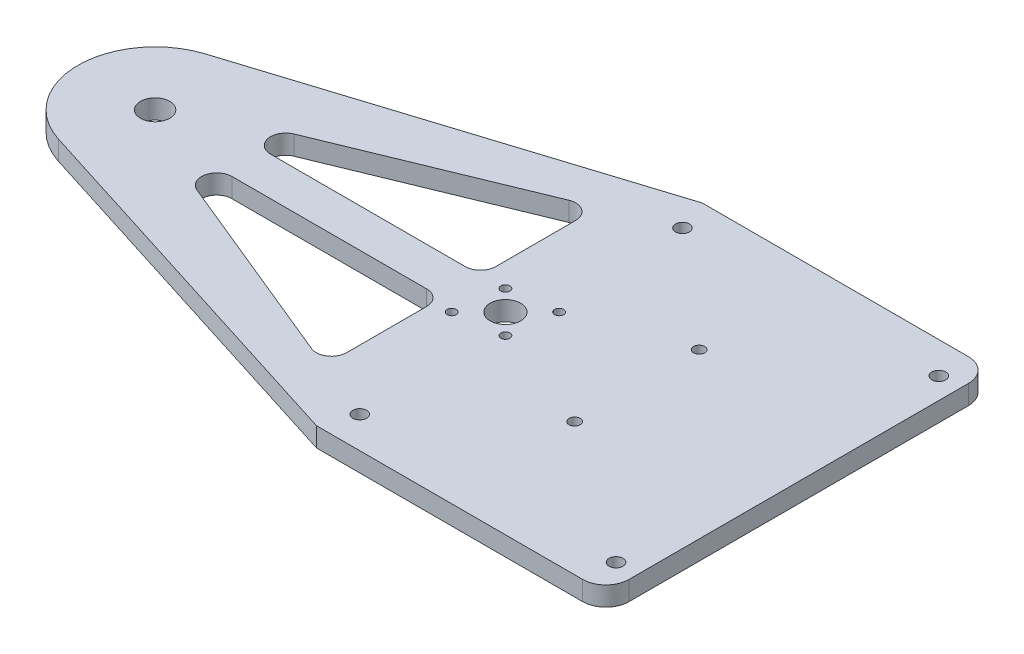
from build123d import *

# Parameters (mm, degrees)
SKETCH1_W           = 95.25
SKETCH1_H           = 127
BOSS_EXTRUDE1_DEPTH = 6.35
BOSS_EXTRUDE3_DEPTH = 6.35
SKETCH5_R           = 4.826
SKETCH5_R_2         = 5.039999953
SKETCH5_R_3         = 1.5
CUT_EXTRUDE1_DEPTH  = 7.35
CUT_EXTRUDE2_DEPTH  = 7.35
FILLET9_R           = 5
FILLET10_R          = 7.62
SKETCH7_R           = 2.2812375
CUT_EXTRUDE3_DEPTH  = 7.35
SKETCH8_R           = 1.830008083
CUT_EXTRUDE4_DEPTH  = 7.35


with BuildPart() as part:
    # Sketch1 → Boss-Extrude1 (new body)
    with BuildSketch(Plane(origin=(0, 0, 0), x_dir=(1, 0, 0), z_dir=(0, 1, 0))):
        Rectangle(SKETCH1_W, SKETCH1_H)
    extrude(amount=BOSS_EXTRUDE1_DEPTH)

    # Sketch4 → Boss-Extrude3 (add)
    with BuildSketch(Plane(origin=(0, 6.35, 0), x_dir=(1, 0, 0), z_dir=(0, 1, 0))):
        with BuildLine():
            Line((-47.625, 63.5), (-171.916018217, 24.219268021))
            ThreePointArc((-171.916018217, 24.219268021), (-189.6618, 0), (-171.916018217, -24.219268021))
            Line((-171.916018217, -24.219268021), (-47.625, -63.5))
            Line((-47.625, -63.5), (-47.625, 63.5))
        make_face()
    extrude(amount=-BOSS_EXTRUDE3_DEPTH)

    # Sketch5 → Cut-Extrude1 (cut, through all)
    with BuildSketch(Plane(origin=(0, 6.35, 0), x_dir=(1, 0, 0), z_dir=(0, 1, 0))):
        with Locations((-164.2618, 0)):
            Circle(SKETCH5_R)
        with Locations((-48.9458, 0)):
            Circle(SKETCH5_R_2)
        with Locations((-40.106965235, 8.838834765)):
            Circle(SKETCH5_R_3)
        with Locations((-57.784634765, -8.838834765)):
            Circle(SKETCH5_R_3)
        with Locations((-55.663314421, 6.717514421)):
            Circle(SKETCH5_R_3)
        with Locations((-42.228285579, -6.717514421)):
            Circle(SKETCH5_R_3)
    extrude(amount=-CUT_EXTRUDE1_DEPTH, mode=Mode.SUBTRACT)

    # Sketch6 → Cut-Extrude2 (cut, through all)
    with BuildSketch(Plane(origin=(0, 6.35, 0), x_dir=(1, 0, 0), z_dir=(0, 1, 0))):
        Polygon((-63.5, 45.163743355), (-157.9118, 6.35), (-63.5, 6.35), align=None)
        Polygon((-63.5, -6.35), (-63.5, -45.163743355), (-157.9118, -6.35), align=None)
    extrude(amount=-CUT_EXTRUDE2_DEPTH, mode=Mode.SUBTRACT)

    # Fillet9
    fillet9_edges = [part.edges().sort_by_distance(p)[0] for p in [
        (-63.5, 3.175, -45.163743355),
        (-63.5, 3.175, -6.35),
        (-157.9118, 3.175, -6.35),
        (-157.9118, 3.175, 6.35),
        (-63.5, 3.175, 6.35),
        (-63.5, 3.175, 45.163743355),
    ]]
    fillet(fillet9_edges, radius=FILLET9_R)

    # Fillet10
    fillet10_edges = [part.edges().sort_by_distance(p)[0] for p in [
        (47.625, 3.175, 63.5),
        (47.625, 3.175, -63.5),
    ]]
    fillet(fillet10_edges, radius=FILLET10_R)

    # Sketch7 → Cut-Extrude3 (cut, through all)
    with BuildSketch(Plane(origin=(0, 6.35, 0), x_dir=(1, 0, 0), z_dir=(0, 1, 0))):
        with Locations((-43.777254611, -53.125383493)):
            Circle(SKETCH7_R)
        with Locations((-43.777254611, 53.125383493)):
            Circle(SKETCH7_R)
        with Locations((40.602254611, 53.125383493)):
            Circle(SKETCH7_R)
        with Locations((40.602254611, -53.125383493)):
            Circle(SKETCH7_R)
    extrude(amount=-CUT_EXTRUDE3_DEPTH, mode=Mode.SUBTRACT)

    # Sketch8 → Cut-Extrude4 (cut, through all)
    with BuildSketch(Plane(origin=(0, 6.35, 0), x_dir=(1, 0, 0), z_dir=(0, 1, 0))):
        with Locations((-6.328465047, -19.828924843)):
            Circle(SKETCH8_R)
        with Locations((-6.328338046, 21.171490961)):
            Circle(SKETCH8_R)
    extrude(amount=-CUT_EXTRUDE4_DEPTH, mode=Mode.SUBTRACT)


solid = part.part
